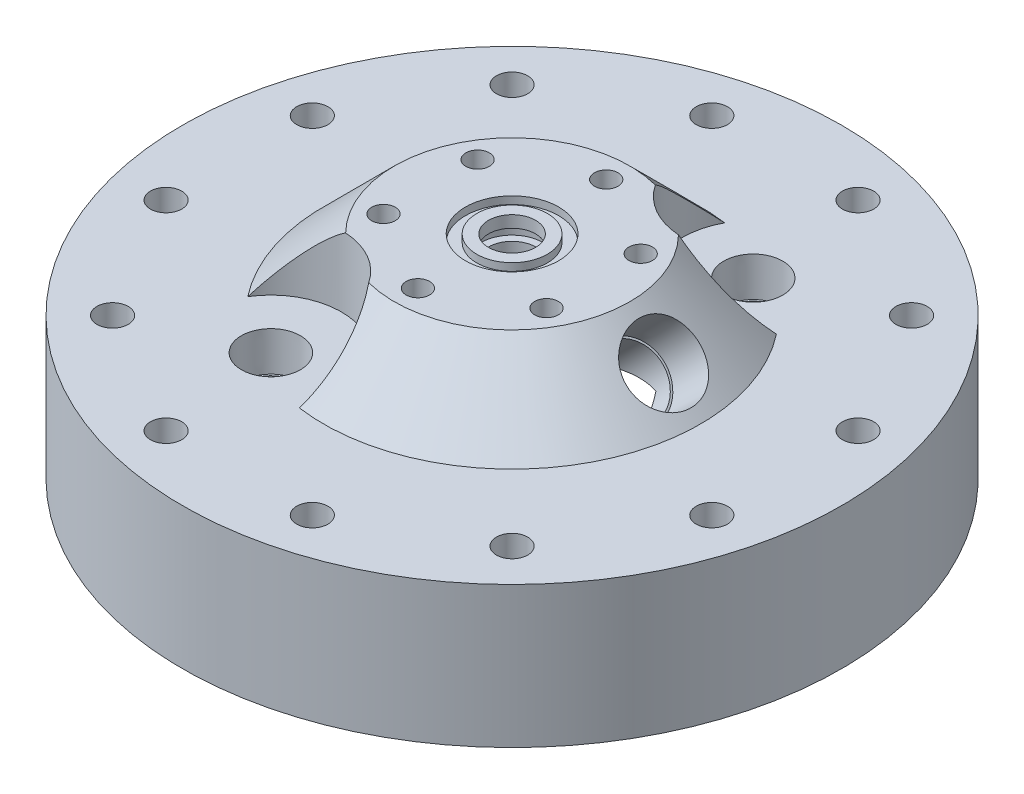
from build123d import *

# Parameters (mm, degrees)
F_5_16_CLEARANCE_HOLE1_D         = 8.4328
CIRPATTERN1_COUNT                = 12
F_1_2_0_5_DIAMETER_HOLE1_D       = 12.7
F_1_1_5_DIAMETER_HOLE1_D         = 38.1
F_1_1_5_DIAMETER_HOLE1_DEPTH     = 19.05
CIRPATTERN2_COUNT                = 6
CIRPATTERN3_COUNT                = 2
F_1_8_0_125_DIAMETER_HOLE1_D     = 3.175
F_1_8_0_125_DIAMETER_HOLE1_DEPTH = 6.35
F_1_8_0_125_DIAMETER_HOLE1_TIP   = 0.953866233


with BuildPart() as part:
    # Sketch1 → Revolve1 (revolve)
    with BuildSketch(Plane.XY, mode=Mode.PRIVATE) as revolve1_sk:
        Polygon((-55.9435, 0), (-88.9, 0), (-88.9, 38.1), (-50.8, 38.1), (-31.75, 57.15), (-12.573, 57.15), (-12.573, 55.118), (-9.525, 55.118), (-9.525, 57.15), (-6.35, 57.15), (-6.35, 53.975), (-8.382, 53.975), (-8.382, 50.927), (-6.35, 50.927), (-6.35, 31.75), (-31.75, 31.75), (-31.75, 19.05), (-50.8, 19.05), (-50.8, 0), (-52.3875, 0), (-52.3875, 2.54), (-55.9435, 2.54), align=None)
    revolve(revolve1_sk.sketch.rotate(Axis((0, 0, 0), (0, 1, 0)), 270), axis=Axis((0, 0, 0), (0, 1, 0)))

    # 5/16 Clearance Hole1 (through all)
    with Locations(Plane(origin=(0, 38.1, 0), x_dir=(1, 0, 0), z_dir=(0, 1, 0))):
        with Locations((-73.603547963, -19.722011237)):
            f_5_16_clearance_hole1 = Hole(F_5_16_CLEARANCE_HOLE1_D / 2)

    # CirPattern1: 5/16 Clearance Hole1 ×12 about axis
    cirpattern1_axis = Axis((0, 0, 0), (0, 1, 0))
    for i in range(1, CIRPATTERN1_COUNT):
        add(f_5_16_clearance_hole1.rotate(cirpattern1_axis, i * 360 / CIRPATTERN1_COUNT), mode=Mode.SUBTRACT)

    # 1/2 (0.5) Diameter Hole1 (through all)
    with Locations(Plane(origin=(0, 57.15, 0), x_dir=(1, 0, 0), z_dir=(0, 1, 0))):
        with Locations((0, 0)):
            Hole(F_1_2_0_5_DIAMETER_HOLE1_D / 2)

    # Sketch11 → 1/2 NPT Tapped Hole1 (revolve, cut)
    with BuildSketch(Plane(origin=(41.275, 47.625, 0), x_dir=(-0.707106781186546, 0.707106781186549, 0), z_dir=(0, 0, 1))):
        Polygon((0, 0), (0, 125.723585695), (8.9281, 125.723585695), (8.9281, 13.462), (9.479726792, 13.462), (9.8827971, 0), align=None)
    revolve(axis=Axis((45.765128061, 52.115128061, 0), (-0.707106781186549, -0.707106781186546, 0)), mode=Mode.SUBTRACT)

    # 1 (1.5) Diameter Hole1
    with Locations(Plane(origin=(0, 57.15, 0), x_dir=(1, 0, 0), z_dir=(0, 1, 0))):
        with Locations((-23.8125, -41.244459855)):
            f_1_1_5_diameter_hole1 = Hole(F_1_1_5_DIAMETER_HOLE1_D / 2, depth=F_1_1_5_DIAMETER_HOLE1_DEPTH)

    # Sketch19 → 3/8 NPT Tapped Hole1 (revolve, cut)
    with BuildSketch(Plane(origin=(-23.8125, 38.1, 41.244459855), x_dir=(0, 0, 1), z_dir=(1, 0, 0))):
        Polygon((0, 0), (0, 26.640582582), (7.1374, 22.352), (7.1374, 10.414), (7.653732494, 10.414), (7.9655416, 0), align=None)
    f_3_8_npt_tapped_hole1 = revolve(axis=Axis((-23.8125, 44.45, 41.244459855), (0, -1, 0)), mode=Mode.SUBTRACT)

    # Sketch21 → 1/4 (0.25) Diameter Hole1 (revolve, cut)
    with BuildSketch(Plane(origin=(21.997045256, 57.15, -12.7), x_dir=(0, 0, 1), z_dir=(1, 0, 0))):
        Polygon((0, 0), (0, 17.909732465), (3.175, 16.002), (3.175, 0), align=None)
    f_1_4_0_25_diameter_hole1 = revolve(axis=Axis((21.997045256, 63.5, -12.7), (0, -1, 0)), mode=Mode.SUBTRACT)

    # CirPattern2: 1/4 (0.25) Diameter Hole1 ×6 about axis
    cirpattern2_axis = Axis((0, 0, 0), (0, 1, 0))
    for i in range(1, CIRPATTERN2_COUNT):
        add(f_1_4_0_25_diameter_hole1.rotate(cirpattern2_axis, i * 360 / CIRPATTERN2_COUNT), mode=Mode.SUBTRACT)

    # CirPattern3: 1 (1.5) Diameter Hole1, 3/8 NPT Tapped Hole1 ×2 about axis
    cirpattern3_axis = Axis((0, 0, 0), (0, 1, 0))
    add([f_1_1_5_diameter_hole1.rotate(cirpattern3_axis, i * 360 / CIRPATTERN3_COUNT) for i in range(1, CIRPATTERN3_COUNT)], mode=Mode.SUBTRACT)
    add([f_3_8_npt_tapped_hole1.rotate(cirpattern3_axis, i * 360 / CIRPATTERN3_COUNT) for i in range(1, CIRPATTERN3_COUNT)], mode=Mode.SUBTRACT)

    # 1/8 (0.125) Diameter Hole1
    with Locations(Plane(origin=(0, 19.05, 0), x_dir=(-1, 0, 0), z_dir=(0, -1, 0))):
        with Locations((0, -44.45)):
            Hole(F_1_8_0_125_DIAMETER_HOLE1_D / 2, depth=F_1_8_0_125_DIAMETER_HOLE1_DEPTH)
            with Locations((0, 0, -(F_1_8_0_125_DIAMETER_HOLE1_DEPTH + F_1_8_0_125_DIAMETER_HOLE1_TIP / 2))):  # 118° drill point
                Cone(0, F_1_8_0_125_DIAMETER_HOLE1_D / 2, F_1_8_0_125_DIAMETER_HOLE1_TIP, mode=Mode.SUBTRACT)


solid = part.part
